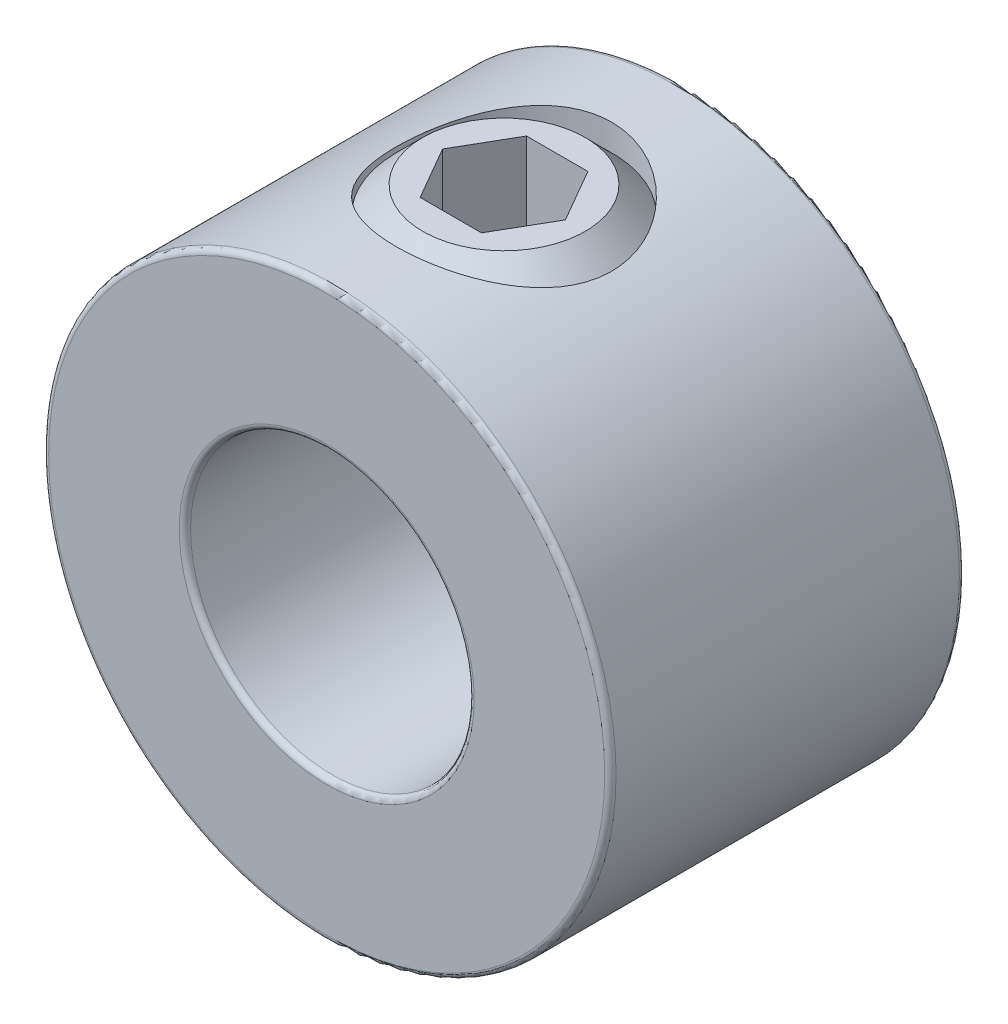
from build123d import *

# Parameters (mm, degrees)
SKETCH1_R          = 6.35
SKETCH1_R_2        = 3.175
EXTRUDE1_DEPTH     = 3.96875
SKETCH2_R          = 2.413
CUT_EXTRUDE1_DEPTH = 7.35
FILLET1_R          = 0.127
CUT_EXTRUDE2_DEPTH = 2.38125


with BuildPart() as part:
    # Sketch1 → Extrude1 (new body, symmetric)
    with BuildSketch(Plane.XY):
        Circle(SKETCH1_R)
        Circle(SKETCH1_R_2, mode=Mode.SUBTRACT)
    extrude(amount=EXTRUDE1_DEPTH, both=True)

    # Sketch2 → Cut-Extrude1 (cut, through all)
    with BuildSketch(Plane(origin=(41.275, 0, 0), x_dir=(0, 0, -1), z_dir=(0, -1, 0))):
        with Locations((0, -41.275)):
            Circle(SKETCH2_R)
    extrude(amount=-CUT_EXTRUDE1_DEPTH, mode=Mode.SUBTRACT)

    # Fillet1
    fillet1_edges = [part.edges().sort_by_distance(p)[0] for p in [
        (-6.35, 0, -3.96875),
        (-6.35, 0, 3.96875),
        (-3.175, 0, -3.96875),
        (-3.175, 0, 3.96875),
    ]]
    fillet(fillet1_edges, radius=FILLET1_R)


with BuildPart() as body_2:
    # Sketch3 → Revolve1 (revolve)
    with BuildSketch(Plane.XY):
        Polygon((-1.819751616, 3.175), (-0.71189806, 3.175), (0, 3.88689806), (0, 6.35), (-1.819751616, 6.35), (-2.413, 5.756751616), (-2.413, 3.768248384), align=None)
    revolve(axis=Axis((0, 3.175, 0), (0, -1, 0)))

    # Sketch4 → Cut-Extrude2 (cut)
    with BuildSketch(Plane(origin=(3.3734375, 6.35, 0), x_dir=(0, 0, -1), z_dir=(0, -1, 0))):
        Polygon((0, -1.998622171), (-1.190625, -2.686029836), (-1.190625, -4.060845164), (0, -4.748252829), (1.190625, -4.060845164), (1.190625, -2.686029836), align=None)
    extrude(amount=CUT_EXTRUDE2_DEPTH, mode=Mode.SUBTRACT)


solid = Compound([part.part, body_2.part])
